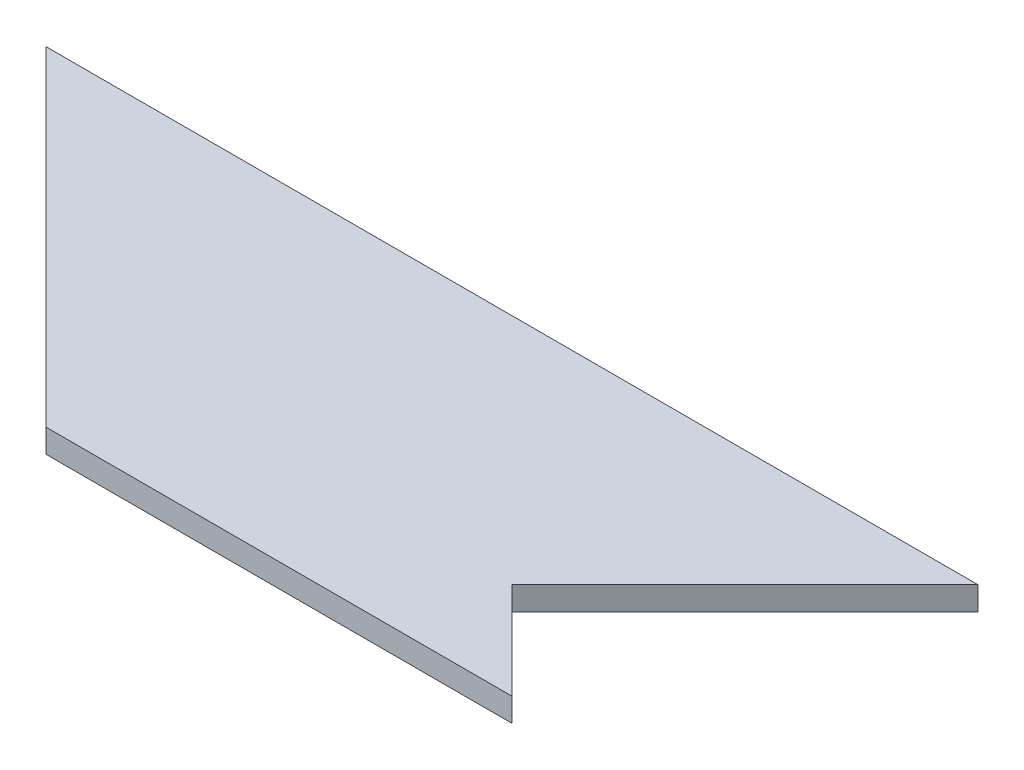
from build123d import *

# Parameters (mm, degrees)
BOSS_EXTRUDE1_DEPTH = 3


with BuildPart() as part:
    # Sketch2 → Boss-Extrude1 (new body)
    with BuildSketch(Plane(origin=(0, 0, 0), x_dir=(1, 0, 0), z_dir=(0, 1, 0))):
        Polygon((-59.4, 16.237850467), (-17.397857198, -25.764292335), (42.002142802, -25.764292335), (29.70151519, -13.460634343), (59.4, 16.237850467), align=None)
    extrude(amount=BOSS_EXTRUDE1_DEPTH)


solid = part.part
